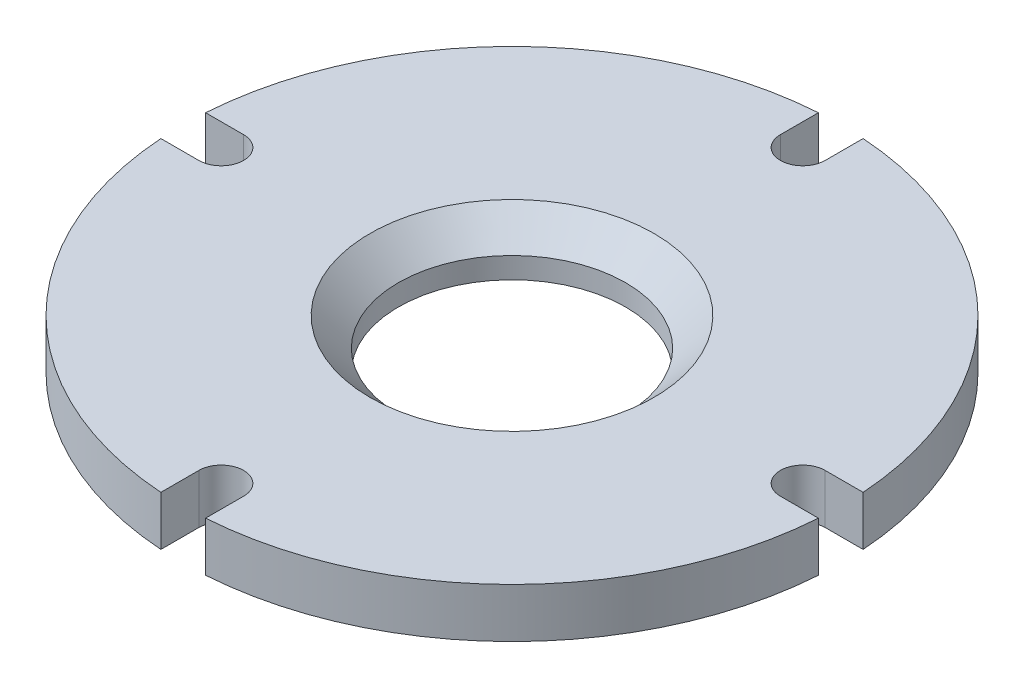
from build123d import *

# Parameters (mm, degrees)
SKETCH1_W           = 36.83
SKETCH1_H           = 5.529791667
SKETCH5_R           = 27.5
BOSS_EXTRUDE1_DEPTH = 0.001
SKETCH19_R          = 12.7
CUT_EXTRUDE6_DEPTH  = 6.530791667
CIRPATTERN1_COUNT   = 4
CUT_EXTRUDE7_DEPTH  = 6.529791667
CIRPATTERN2_COUNT   = 4
CHAMFER1_SIZE       = 3.175
SKETCH28_R          = 16.2052
SKETCH28_R_2        = 13.97
CUT_EXTRUDE17_DEPTH = 1.3208


with BuildPart() as part:
    # Sketch1 → Revolve1 (revolve)
    with BuildSketch(Plane(origin=(0, 0, 0), x_dir=(-1, 0, 0), z_dir=(0, 0, -1))):
        with Locations((-18.415, -2.764895834)):
            Rectangle(SKETCH1_W, SKETCH1_H)
    revolve(axis=Axis((0, -5.529791667, 0), (0, 1, 0)))

    # Sketch5 → Boss-Extrude1 (add)
    with BuildSketch(Plane.XZ.offset(5.529791667)):
        Circle(SKETCH5_R)
    extrude(amount=BOSS_EXTRUDE1_DEPTH)

    # Sketch12 → #4-40 Tapped Hole1 (revolve, cut)
    with BuildSketch(Plane(origin=(-14.601755032, -5.530791667, 14.601755032), x_dir=(0, 0, -1), z_dir=(1, 0, 0))):
        Polygon((0, 0), (0, 3.981152758), (1.1303, 3.302), (1.1303, 0), align=None)
    f_4_40_tapped_hole1 = revolve(axis=Axis((-14.601755032, -11.880791667, 14.601755032), (0, 1, 0)), mode=Mode.SUBTRACT)

    # Sketch19 → Cut-Extrude6 (cut, through all)
    with BuildSketch(Plane.XZ.offset(5.530791667)):
        Circle(SKETCH19_R)
    extrude(amount=-CUT_EXTRUDE6_DEPTH, mode=Mode.SUBTRACT)

    # CirPattern1: #4-40 Tapped Hole1 ×4 about axis
    cirpattern1_axis = Axis((0, 0, 0), (0, 1, 0))
    for i in range(1, CIRPATTERN1_COUNT):
        add(f_4_40_tapped_hole1.rotate(cirpattern1_axis, i * 360 / CIRPATTERN1_COUNT), mode=Mode.SUBTRACT)

    # Sketch20 → Cut-Extrude7 (cut, through all)
    with BuildSketch(Plane(origin=(0, -5.529791667, 0), x_dir=(-1, 0, 0), z_dir=(0, -1, 0))):
        with BuildLine():
            Line((2.5, -32.5), (2.5, -42.5))
            ThreePointArc((2.5, -42.5), (0, -45), (-2.5, -42.5))
            Line((-2.5, -42.5), (-2.5, -32.5))
            ThreePointArc((-2.5, -32.5), (0, -30), (2.5, -32.5))
        make_face()
    cut_extrude7 = extrude(amount=-CUT_EXTRUDE7_DEPTH, mode=Mode.SUBTRACT)

    # CirPattern2: Cut-Extrude7 ×4 about axis
    cirpattern2_axis = Axis((0, 0, 0), (0, 1, 0))
    for i in range(1, CIRPATTERN2_COUNT):
        add(cut_extrude7.rotate(cirpattern2_axis, i * 360 / CIRPATTERN2_COUNT), mode=Mode.SUBTRACT)

    # Chamfer1
    chamfer1_edges = [part.edges().sort_by_distance(p)[0] for p in [
        (-12.7, 0, 0),
    ]]
    chamfer(chamfer1_edges, length=CHAMFER1_SIZE)

    # Sketch28 → Cut-Extrude17 (cut)
    with BuildSketch(Plane.XZ.offset(5.530791667)):
        Circle(SKETCH28_R)
        Circle(SKETCH28_R_2, mode=Mode.SUBTRACT)
    extrude(amount=-CUT_EXTRUDE17_DEPTH, mode=Mode.SUBTRACT)


solid = part.part
